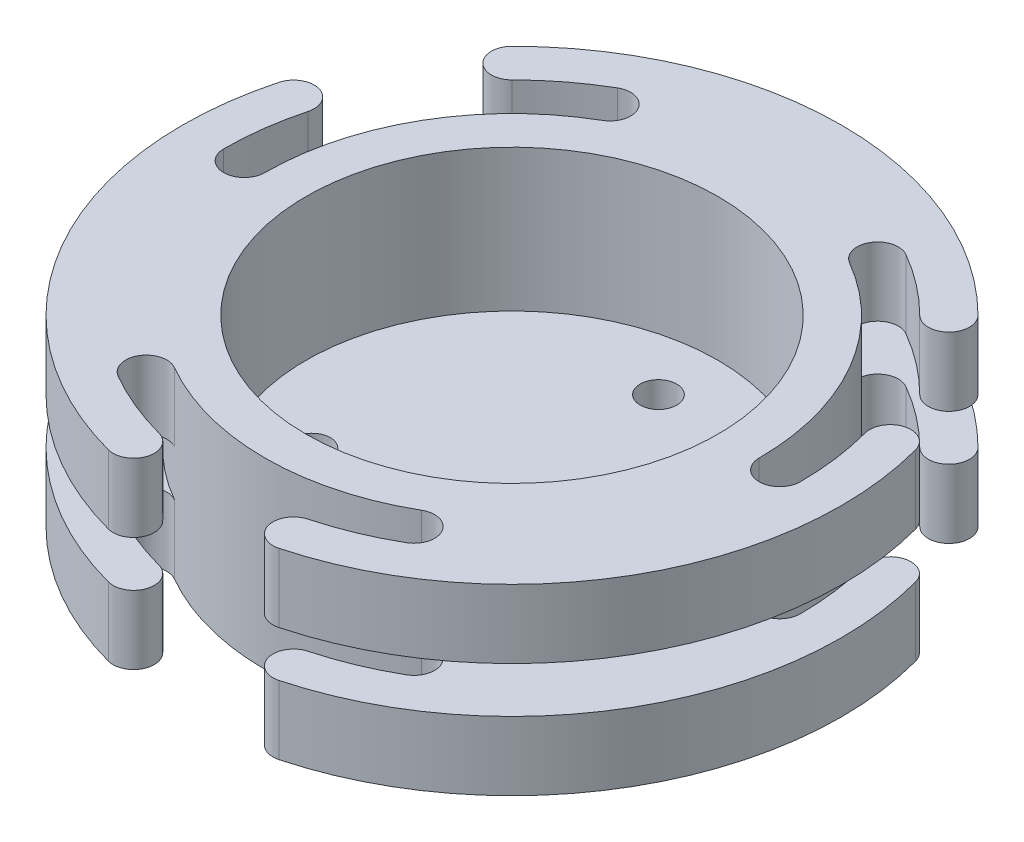
from build123d import *

# Parameters (mm, degrees)
ESQUISSE1_R             = 31.5
ESQUISSE1_R_2           = 22.5
BOSS_EXTRU_1_DEPTH      = 20
ENL_V_MAT_EXTRU_1_DEPTH = 21
BOSS_EXTRU_2_DEPTH      = 20
ESQUISSE4_R             = 22.5
BOSS_EXTRU_3_DEPTH      = 4.5
ENL_V_MAT_EXTRU_2_REACH = 6.5
ESQUISSE5_R             = 2
ESQUISSE6_W             = 9
ESQUISSE6_H             = 5


with BuildPart() as part:
    # Esquisse1 → Boss.-Extru.1 (new body)
    with BuildSketch(Plane(origin=(0, 0, 0), x_dir=(1, 0, 0), z_dir=(0, 1, 0))):
        Circle(ESQUISSE1_R)
        Circle(ESQUISSE1_R_2, mode=Mode.SUBTRACT)
    extrude(amount=BOSS_EXTRU_1_DEPTH)

    # Esquisse2 → Enlèv. mat.-Extru.1 (cut, through all)
    with BuildSketch(Plane(origin=(0, 20, 0), x_dir=(1, 0, 0), z_dir=(0, 1, 0))):
        with BuildLine():
            ThreePointArc((-15.75, 27.279800219), (-27.279800219, 15.75), (-31.5, 0))
            ThreePointArc((-31.5, 0), (-29.25, -2.25), (-27, 0))
            ThreePointArc((-27, 0), (-23.382685902, 13.5), (-13.5, 23.382685902))
            ThreePointArc((-13.5, 23.382685902), (-12.676442841, 26.456243061), (-15.75, 27.279800219))
        make_face()
        with BuildLine():
            ThreePointArc((31.5, 0), (27.279800219, 15.75), (15.75, 27.279800219))
            ThreePointArc((15.75, 27.279800219), (12.676442841, 26.456243061), (13.5, 23.382685902))
            ThreePointArc((13.5, 23.382685902), (23.382685902, 13.5), (27, 0))
            ThreePointArc((27, 0), (29.25, -2.25), (31.5, 0))
        make_face()
        with BuildLine():
            ThreePointArc((-15.75, -27.279800219), (0, -31.5), (15.75, -27.279800219))
            ThreePointArc((15.75, -27.279800219), (16.573557159, -24.206243061), (13.5, -23.382685902))
            ThreePointArc((13.5, -23.382685902), (0, -27), (-13.5, -23.382685902))
            ThreePointArc((-13.5, -23.382685902), (-16.573557159, -24.206243061), (-15.75, -27.279800219))
        make_face()
    extrude(amount=-ENL_V_MAT_EXTRU_1_DEPTH, mode=Mode.SUBTRACT)

    # Esquisse3 → Boss.-Extru.2 (add)
    with BuildSketch(Plane(origin=(0, 20, 0), x_dir=(1, 0, 0), z_dir=(0, 1, 0))):
        with BuildLine():
            ThreePointArc((25.455844123, 25.455844123), (0, 36), (-25.455844123, 25.455844123))
            ThreePointArc((-25.455844123, 25.455844123), (-25.455844123, 22.273863607), (-22.273863607, 22.273863607))
            ThreePointArc((-22.273863607, 22.273863607), (0, 31.5), (22.273863607, 22.273863607))
            ThreePointArc((22.273863607, 22.273863607), (25.455844123, 22.273863607), (25.455844123, 25.455844123))
        make_face()
        with BuildLine():
            ThreePointArc((9.317485624, -34.773329746), (31.176914536, -18), (34.773329746, 9.317485624))
            ThreePointArc((34.773329746, 9.317485624), (32.017653786, 10.908475881), (30.426663528, 8.152799921))
            ThreePointArc((30.426663528, 8.152799921), (27.279800219, -15.75), (8.152799921, -30.426663528))
            ThreePointArc((8.152799921, -30.426663528), (6.561809663, -33.182339489), (9.317485624, -34.773329746))
        make_face()
        with BuildLine():
            ThreePointArc((-34.773329746, 9.317485624), (-31.176914536, -18), (-9.317485624, -34.773329746))
            ThreePointArc((-9.317485624, -34.773329746), (-6.561809663, -33.182339489), (-8.152799921, -30.426663528))
            ThreePointArc((-8.152799921, -30.426663528), (-27.279800219, -15.75), (-30.426663528, 8.152799921))
            ThreePointArc((-30.426663528, 8.152799921), (-32.017653786, 10.908475881), (-34.773329746, 9.317485624))
        make_face()
    extrude(amount=-BOSS_EXTRU_2_DEPTH)

    # Esquisse4 → Boss.-Extru.3 (add)
    with BuildSketch(Plane.XZ):
        Circle(ESQUISSE4_R)
    extrude(amount=-BOSS_EXTRU_3_DEPTH)

    # Esquisse5 → Enlèv. mat.-Extru.2 (cut, up to next)
    with BuildSketch(Plane(origin=(0, 4.5, 0), x_dir=(1, 0, 0), z_dir=(0, 1, 0)), mode=Mode.PRIVATE) as enl_v_mat_extru_2_sk1:
        with Locations((0, 16)):
            Circle(ESQUISSE5_R)
    enl_v_mat_extru_2_tool1 = extrude(enl_v_mat_extru_2_sk1.sketch, amount=-ENL_V_MAT_EXTRU_2_REACH, mode=Mode.PRIVATE) & part.part
    add(enl_v_mat_extru_2_tool1.solids().sort_by_distance((0, 4.5, -16))[0], mode=Mode.SUBTRACT)
    # Esquisse5 → Enlèv. mat.-Extru.2 (cut, up to next)
    with BuildSketch(Plane(origin=(0, 4.5, 0), x_dir=(1, 0, 0), z_dir=(0, 1, 0)), mode=Mode.PRIVATE) as enl_v_mat_extru_2_sk2:
        with Locations((13.856406461, -8)):
            Circle(ESQUISSE5_R)
    enl_v_mat_extru_2_tool2 = extrude(enl_v_mat_extru_2_sk2.sketch, amount=-ENL_V_MAT_EXTRU_2_REACH, mode=Mode.PRIVATE) & part.part
    add(enl_v_mat_extru_2_tool2.solids().sort_by_distance((13.856406, 4.5, 8))[0], mode=Mode.SUBTRACT)
    # Esquisse5 → Enlèv. mat.-Extru.2 (cut, up to next)
    with BuildSketch(Plane(origin=(0, 4.5, 0), x_dir=(1, 0, 0), z_dir=(0, 1, 0)), mode=Mode.PRIVATE) as enl_v_mat_extru_2_sk3:
        with Locations((-13.856406461, -8)):
            Circle(ESQUISSE5_R)
    enl_v_mat_extru_2_tool3 = extrude(enl_v_mat_extru_2_sk3.sketch, amount=-ENL_V_MAT_EXTRU_2_REACH, mode=Mode.PRIVATE) & part.part
    add(enl_v_mat_extru_2_tool3.solids().sort_by_distance((-13.856406, 4.5, 8))[0], mode=Mode.SUBTRACT)

    # Esquisse6 → Enlèvement de matière-Révolution1 (revolve, cut)
    with BuildSketch(Plane(origin=(0, 0, 0), x_dir=(0, 0, -1), z_dir=(1, 0, 0))):
        with Locations((31.5, 10)):
            Rectangle(ESQUISSE6_W, ESQUISSE6_H)
    revolve(axis=Axis((0, 10, 0), (0, -1, 0)), mode=Mode.SUBTRACT)


solid = part.part
